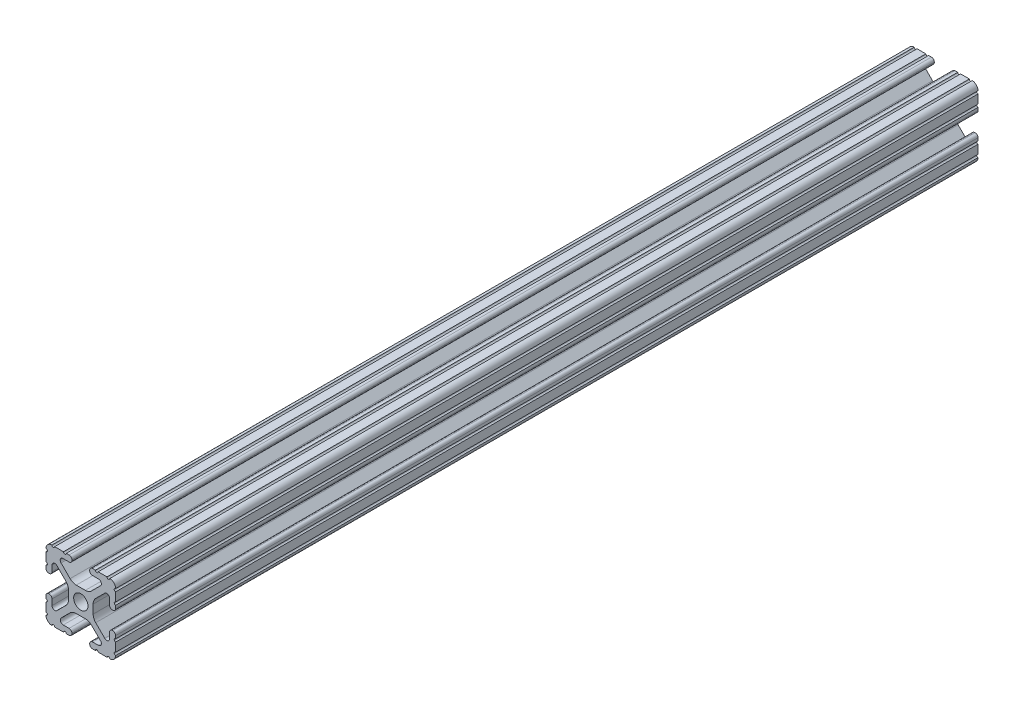
from build123d import *

# Parameters (mm, degrees)
SKETCH1_R           = 2.6035
BOSS_EXTRUDE1_DEPTH = 304.8
SKETCH2_W           = 54.534078776
SKETCH2_H           = 52.309705205
CUT_EXTRUDE1_DEPTH  = 294.894


with BuildPart() as part:
    # Sketch1 → Boss-Extrude1 (new body, symmetric)
    with BuildSketch(Plane.XY):
        with BuildLine():
            Line((-7.179650497, -8.645192506), (-3.952270251, -5.423690499))
            ThreePointArc((-3.952270251, -5.423690499), (-2.922936451, -4.736929036), (-1.709253557, -4.4958))
            Line((-1.709253557, -4.4958), (1.709253557, -4.4958))
            ThreePointArc((1.709253557, -4.4958), (2.922936451, -4.736929036), (3.952270251, -5.423690499))
            Line((3.952270251, -5.423690499), (7.179650497, -8.645192506))
            ThreePointArc((7.179650497, -8.645192506), (7.41473083, -9.822813117), (6.416408329, -10.4902))
            Line((6.416408329, -10.4902), (4.287512407, -10.4902))
            ThreePointArc((4.287512407, -10.4902), (3.54574862, -10.79744862), (3.2385, -11.539212407))
            Line((3.2385, -11.539212407), (3.2385, -11.650987593))
            ThreePointArc((3.2385, -11.650987593), (3.54574862, -12.39275138), (4.287512407, -12.7))
            Line((4.287512407, -12.7), (5.317126718, -12.7))
            ThreePointArc((5.317126718, -12.7), (5.825126718, -12.192), (6.333126718, -12.7))
            Line((6.333126718, -12.7), (9.550443118, -12.7))
            ThreePointArc((9.550443118, -12.7), (10.058366869, -12.192000006), (10.566443095, -12.699847501))
            ThreePointArc((10.566443095, -12.699847501), (12.082537762, -12.08250727), (12.699846982, -10.566399977))
            ThreePointArc((12.699846982, -10.566399977), (12.192000006, -10.058323491), (12.7, -9.5504))
            Line((12.7, -9.5504), (12.7, -6.3330836))
            ThreePointArc((12.7, -6.3330836), (12.192, -5.8250836), (12.7, -5.3170836))
            Line((12.7, -5.3170836), (12.7, -4.287469289))
            ThreePointArc((12.7, -4.287469289), (12.39275138, -3.545705502), (11.650987593, -3.238456882))
            Line((11.650987593, -3.238456882), (11.539212407, -3.238456882))
            ThreePointArc((11.539212407, -3.238456882), (10.79744862, -3.545705502), (10.4902, -4.287469289))
            Line((10.4902, -4.287469289), (10.4902, -6.402089023))
            ThreePointArc((10.4902, -6.402089023), (9.856505071, -7.351067942), (8.737131347, -7.129408934))
            Line((8.737131347, -7.129408934), (5.441005833, -3.840816462))
            ThreePointArc((5.441005833, -3.840816462), (4.750877967, -2.809883091), (4.5085, -1.593185507))
            Line((4.5085, -1.593185507), (4.5085, 1.593185507))
            ThreePointArc((4.5085, 1.593185507), (4.750877967, 2.809883091), (5.441005833, 3.840816462))
            Line((5.441005833, 3.840816462), (8.737131347, 7.129408934))
            ThreePointArc((8.737131347, 7.129408934), (9.856505071, 7.351067942), (10.4902, 6.402089023))
            Line((10.4902, 6.402089023), (10.4902, 4.287469289))
            ThreePointArc((10.4902, 4.287469289), (10.79744862, 3.545705502), (11.539212407, 3.238456882))
            Line((11.539212407, 3.238456882), (11.650987593, 3.238456882))
            ThreePointArc((11.650987593, 3.238456882), (12.39275138, 3.545705502), (12.7, 4.287469289))
            Line((12.7, 4.287469289), (12.7, 5.3170836))
            ThreePointArc((12.7, 5.3170836), (12.192, 5.8250836), (12.7, 6.3330836))
            Line((12.7, 6.3330836), (12.7, 9.5504))
            ThreePointArc((12.7, 9.5504), (12.192000006, 10.058323491), (12.699846982, 10.566399977))
            ThreePointArc((12.699846982, 10.566399977), (12.082537762, 12.08250727), (10.566443095, 12.699847501))
            ThreePointArc((10.566443095, 12.699847501), (10.058366869, 12.192000006), (9.550443118, 12.7))
            Line((9.550443118, 12.7), (6.333126718, 12.7))
            ThreePointArc((6.333126718, 12.7), (5.825126718, 12.192), (5.317126718, 12.7))
            Line((5.317126718, 12.7), (4.287512407, 12.7))
            ThreePointArc((4.287512407, 12.7), (3.54574862, 12.39275138), (3.2385, 11.650987593))
            Line((3.2385, 11.650987593), (3.2385, 11.539212407))
            ThreePointArc((3.2385, 11.539212407), (3.54574862, 10.79744862), (4.287512407, 10.4902))
            Line((4.287512407, 10.4902), (6.476788598, 10.4902))
            ThreePointArc((6.476788598, 10.4902), (7.432222385, 9.85140422), (7.207036008, 8.724370562))
            Line((7.207036008, 8.724370562), (3.898272566, 5.423169045))
            ThreePointArc((3.898272566, 5.423169045), (2.869120213, 4.736787962), (1.655778399, 4.4958))
            Line((1.655778399, 4.4958), (-1.655778399, 4.4958))
            ThreePointArc((-1.655778399, 4.4958), (-2.869120213, 4.736787962), (-3.898272566, 5.423169045))
            Line((-3.898272566, 5.423169045), (-7.207036008, 8.724370562))
            ThreePointArc((-7.207036008, 8.724370562), (-7.432222385, 9.85140422), (-6.476788598, 10.4902))
            Line((-6.476788598, 10.4902), (-4.287512407, 10.4902))
            ThreePointArc((-4.287512407, 10.4902), (-3.54574862, 10.79744862), (-3.2385, 11.539212407))
            Line((-3.2385, 11.539212407), (-3.2385, 11.650987593))
            ThreePointArc((-3.2385, 11.650987593), (-3.54574862, 12.39275138), (-4.287512407, 12.7))
            Line((-4.287512407, 12.7), (-5.317126718, 12.7))
            ThreePointArc((-5.317126718, 12.7), (-5.825126718, 12.192), (-6.333126718, 12.7))
            Line((-6.333126718, 12.7), (-9.550443118, 12.7))
            ThreePointArc((-9.550443118, 12.7), (-10.058366869, 12.192000006), (-10.566443095, 12.699847501))
            ThreePointArc((-10.566443095, 12.699847501), (-12.082537762, 12.08250727), (-12.699846982, 10.566399977))
            ThreePointArc((-12.699846982, 10.566399977), (-12.192000006, 10.058323491), (-12.7, 9.5504))
            Line((-12.7, 9.5504), (-12.7, 6.3330836))
            ThreePointArc((-12.7, 6.3330836), (-12.192, 5.8250836), (-12.7, 5.3170836))
            Line((-12.7, 5.3170836), (-12.7, 4.287469289))
            ThreePointArc((-12.7, 4.287469289), (-12.39275138, 3.545705502), (-11.650987593, 3.238456882))
            Line((-11.650987593, 3.238456882), (-11.539212407, 3.238456882))
            ThreePointArc((-11.539212407, 3.238456882), (-10.79744862, 3.545705502), (-10.4902, 4.287469289))
            Line((-10.4902, 4.287469289), (-10.4902, 6.402089023))
            ThreePointArc((-10.4902, 6.402089023), (-9.856505071, 7.351067942), (-8.737131347, 7.129408934))
            Line((-8.737131347, 7.129408934), (-5.441005833, 3.840816462))
            ThreePointArc((-5.441005833, 3.840816462), (-4.750877967, 2.809883091), (-4.5085, 1.593185507))
            Line((-4.5085, 1.593185507), (-4.5085, -1.593185507))
            ThreePointArc((-4.5085, -1.593185507), (-4.750877967, -2.809883091), (-5.441005833, -3.840816462))
            Line((-5.441005833, -3.840816462), (-8.737131347, -7.129408934))
            ThreePointArc((-8.737131347, -7.129408934), (-9.856505071, -7.351067942), (-10.4902, -6.402089023))
            Line((-10.4902, -6.402089023), (-10.4902, -4.287469289))
            ThreePointArc((-10.4902, -4.287469289), (-10.79744862, -3.545705502), (-11.539212407, -3.238456882))
            Line((-11.539212407, -3.238456882), (-11.650987593, -3.238456882))
            ThreePointArc((-11.650987593, -3.238456882), (-12.39275138, -3.545705502), (-12.7, -4.287469289))
            Line((-12.7, -4.287469289), (-12.7, -5.3170836))
            ThreePointArc((-12.7, -5.3170836), (-12.192, -5.8250836), (-12.7, -6.3330836))
            Line((-12.7, -6.3330836), (-12.7, -9.5504))
            ThreePointArc((-12.7, -9.5504), (-12.192000006, -10.058323491), (-12.699846982, -10.566399977))
            ThreePointArc((-12.699846982, -10.566399977), (-12.082537762, -12.08250727), (-10.566443095, -12.699847501))
            ThreePointArc((-10.566443095, -12.699847501), (-10.058366869, -12.192000006), (-9.550443118, -12.7))
            Line((-9.550443118, -12.7), (-6.333126718, -12.7))
            ThreePointArc((-6.333126718, -12.7), (-5.825126718, -12.192), (-5.317126718, -12.7))
            Line((-5.317126718, -12.7), (-4.287512407, -12.7))
            ThreePointArc((-4.287512407, -12.7), (-3.54574862, -12.39275138), (-3.2385, -11.650987593))
            Line((-3.2385, -11.650987593), (-3.2385, -11.539212407))
            ThreePointArc((-3.2385, -11.539212407), (-3.54574862, -10.79744862), (-4.287512407, -10.4902))
            Line((-4.287512407, -10.4902), (-6.416408329, -10.4902))
            ThreePointArc((-6.416408329, -10.4902), (-7.41473083, -9.822813117), (-7.179650497, -8.645192506))
        make_face()
        Circle(SKETCH1_R, mode=Mode.SUBTRACT)
    extrude(amount=BOSS_EXTRUDE1_DEPTH, both=True)

    # Sketch2 → Cut-Extrude1 (cut)
    with BuildSketch(Plane.XY.offset(304.8)):
        with Locations((3.588199908, -2.803361197)):
            Rectangle(SKETCH2_W, SKETCH2_H)
    extrude(amount=-CUT_EXTRUDE1_DEPTH, mode=Mode.SUBTRACT)


solid = part.part
